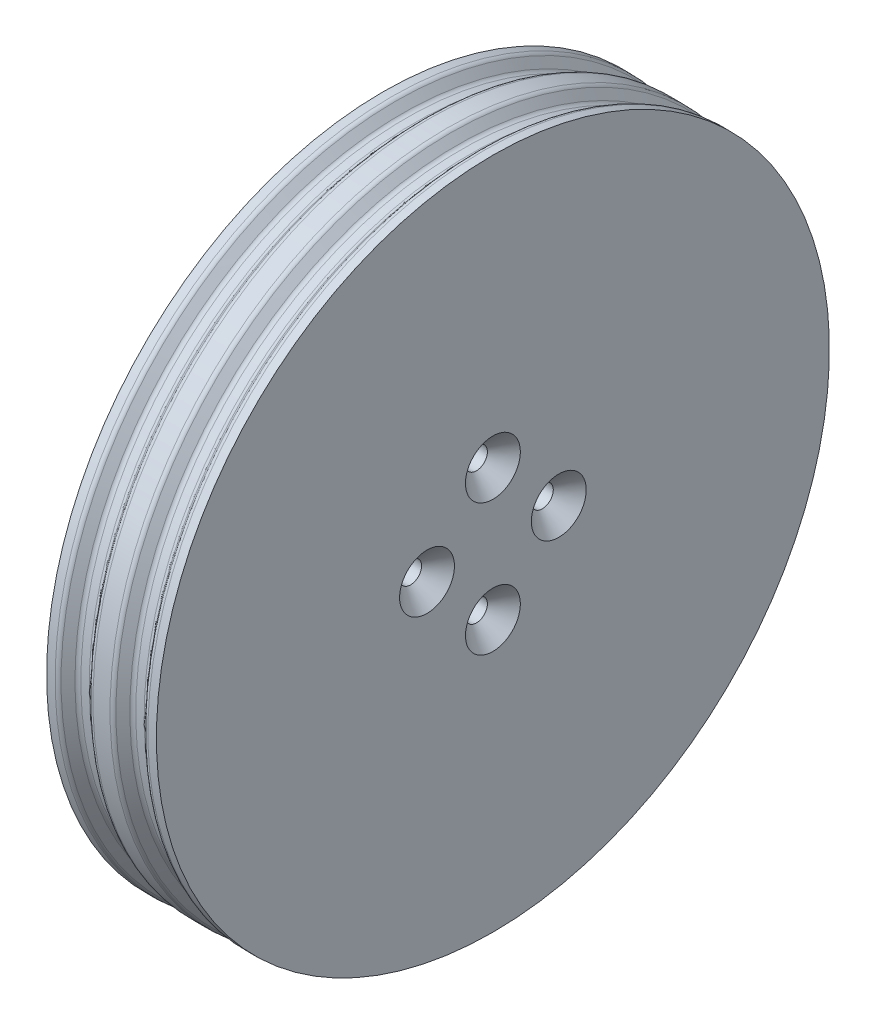
from build123d import *

# Parameters (mm, degrees)
SCHIZZO2_R               = 1
TAGLIO_ESTRUSIONE1_DEPTH = 10
SMUSSO1_SIZE             = 1.5
RACCORDO1_R              = 0.5


with BuildPart() as part:
    # Schizzo1 → Rivoluzione1 (revolve)
    with BuildSketch(Plane.XY):
        Polygon((0, 0), (0, 17.3), (-7, 17.3), (-7, 30.65), (-6, 30.65), (-5.102243061, 29.65), (-3.897756939, 29.65), (-3, 30.65), (-1, 30.65), (-0.102243061, 29.65), (1.102243061, 29.65), (2, 30.65), (3, 30.65), (3, 0), align=None)
    revolve(axis=Axis((0, 0, 0), (1, 0, 0)))

    # Schizzo2 → Taglio-Estrusione1 (cut)
    with BuildSketch(Plane(origin=(3, 0, 0), x_dir=(0, 0, -1), z_dir=(1, 0, 0))):
        with Locations((0, 6)):
            Circle(SCHIZZO2_R)
        with Locations((6, 0)):
            Circle(SCHIZZO2_R)
        with Locations((0, -6)):
            Circle(SCHIZZO2_R)
        with Locations((-6, 0)):
            Circle(SCHIZZO2_R)
    extrude(amount=-TAGLIO_ESTRUSIONE1_DEPTH, mode=Mode.SUBTRACT)

    # Smusso1
    smusso1_edges = [part.edges().sort_by_distance(p)[0] for p in [
        (3, 6, 1),
        (3, 0, -5),
        (3, -6, 1),
        (3, 0, 7),
    ]]
    chamfer(smusso1_edges, length=SMUSSO1_SIZE)

    # Raccordo1
    raccordo1_edges = [part.edges().sort_by_distance(p)[0] for p in [
        (2, -30.65, 0),
        (1.102243061, -29.65, 0),
        (-0.102243061, -29.65, 0),
        (-1, -30.65, 0),
        (-3, -30.65, 0),
        (-3.897756939, -29.65, 0),
        (-5.102243061, -29.65, 0),
        (-6, -30.65, 0),
    ]]
    fillet(raccordo1_edges, radius=RACCORDO1_R)


solid = part.part
